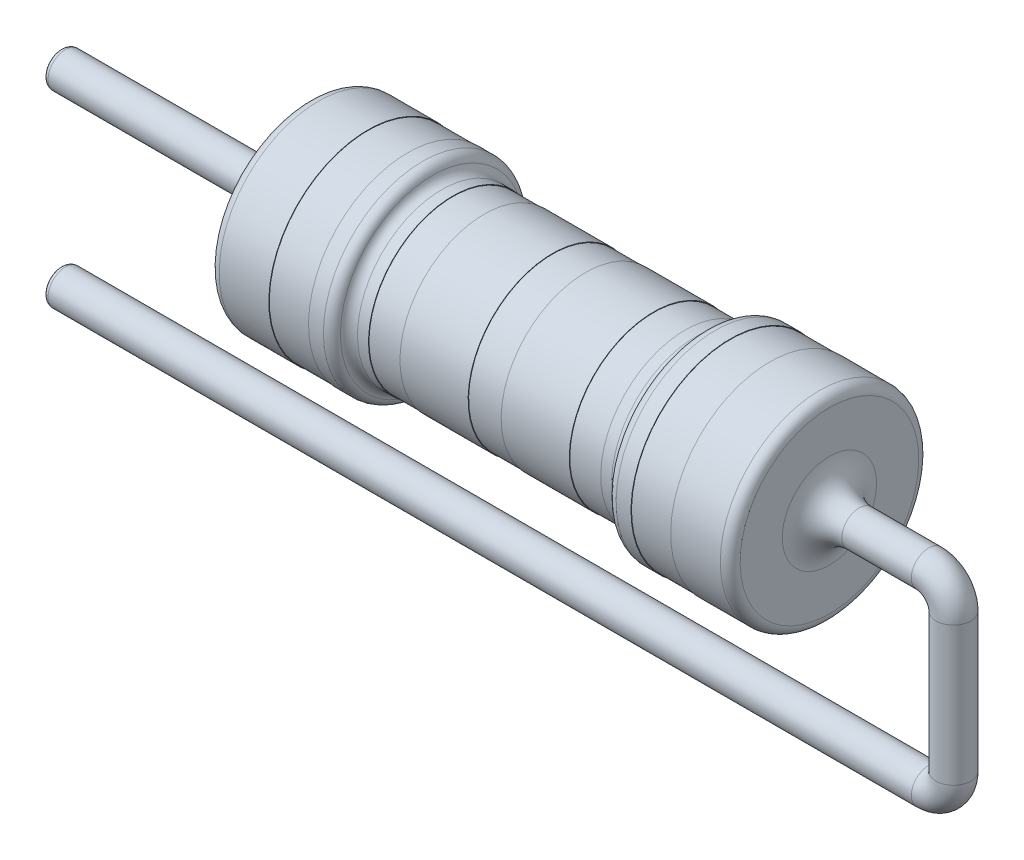
from build123d import *

# Parameters (mm, degrees)
FILLET2_R  = 0.2
FILLET3_R  = 0.2
FILLET4_R  = 0.2
FILLET5_R  = 0.2
FILLET6_R  = 0.2
SKETCH3_R  = 0.35
SKETCH4_R  = 0.35
FILLET17_R = 0.1
FILLET18_R = 0.6


with BuildPart() as part:
    # Sketch1 → Revolve1 (revolve)
    with BuildSketch(Plane.XY):
        Polygon((-5.25, 0), (5.25, 0), (5.25, -2), (4.05, -2), (4.05, -1.99), (3.25, -1.99), (3.25, -2), (2.75, -2), (2.75, -1.7), (2.340690061, -1.7), (2.340690061, -1.69), (1.70680528, -1.69), (1.70680528, -1.7), (0.332543076, -1.7), (0.332543076, -1.69), (-0.332543076, -1.69), (-0.332543076, -1.7), (-1.70680528, -1.7), (-1.70680528, -1.69), (-2.340690061, -1.69), (-2.340690061, -1.7), (-2.75, -1.7), (-2.75, -2), (-3.25, -2), (-3.25, -1.99), (-4.05, -1.99), (-4.05, -2), (-5.25, -2), align=None)
    revolve(axis=Axis((-5.25, 0, 0), (1, 0, 0)))

    # Fillet2
    fillet2_edges = [part.edges().sort_by_distance(p)[0] for p in [
        (-2.75, 2, 0),
    ]]
    fillet(fillet2_edges, radius=FILLET2_R)

    # Fillet3
    fillet3_edges = [part.edges().sort_by_distance(p)[0] for p in [
        (-2.75, 1.7, 0),
        (2.75, 2, 0),
    ]]
    fillet(fillet3_edges, radius=FILLET3_R)

    # Fillet4
    fillet4_edges = [part.edges().sort_by_distance(p)[0] for p in [
        (2.75, 1.7, 0),
    ]]
    fillet(fillet4_edges, radius=FILLET4_R)

    # Fillet5
    fillet5_edges = [part.edges().sort_by_distance(p)[0] for p in [
        (-5.25, 2, 0),
    ]]
    fillet(fillet5_edges, radius=FILLET5_R)

    # Fillet6
    fillet6_edges = [part.edges().sort_by_distance(p)[0] for p in [
        (5.25, 2, 0),
    ]]
    fillet(fillet6_edges, radius=FILLET6_R)

    # Sweep5: sweep along a curve in space
    with BuildLine() as sweep5_path:
        Line((5.25, 0, 0), (7.25, 0, 0))
        ThreePointArc((7.75, -0.5, 0), (7.603553391, -0.146446609, 0), (7.25, 0, 0))
        Line((7.75, -0.5, 0), (7.75, -3.296313033, 0))
        ThreePointArc((7.25, -3.796313033, 0), (7.603553391, -3.649866424, 0), (7.75, -3.296313033, 0))
        Line((7.25, -3.796313033, 0), (-10.25, -3.796313033, 0))
    # Sketch3 → Sweep5 (sweep)
    with BuildSketch(Plane(origin=(5.25, 0, 0), x_dir=(0, 0, -1), z_dir=(1, 0, 0))):
        Circle(SKETCH3_R)
    sweep(path=sweep5_path.line)

    # Sweep6: sweep along a curve in space
    with BuildLine() as sweep6_path:
        Line((-5.25, 0, 0), (-10.25, 0, 0))
    # Sketch4 → Sweep6 (sweep)
    with BuildSketch(Plane.ZY.offset(5.25)):
        Circle(SKETCH4_R)
    sweep(path=sweep6_path.line)

    # Fillet17
    fillet17_edges = [part.edges().sort_by_distance(p)[0] for p in [
        (-10.25, -3.796313033, 0.35),
        (-10.25, 0, -0.35),
    ]]
    fillet(fillet17_edges, radius=FILLET17_R)

    # Fillet18
    fillet18_edges = [part.edges().sort_by_distance(p)[0] for p in [
        (5.25, 0, 0.35),
        (-5.25, 0, -0.35),
    ]]
    fillet(fillet18_edges, radius=FILLET18_R)


solid = part.part
